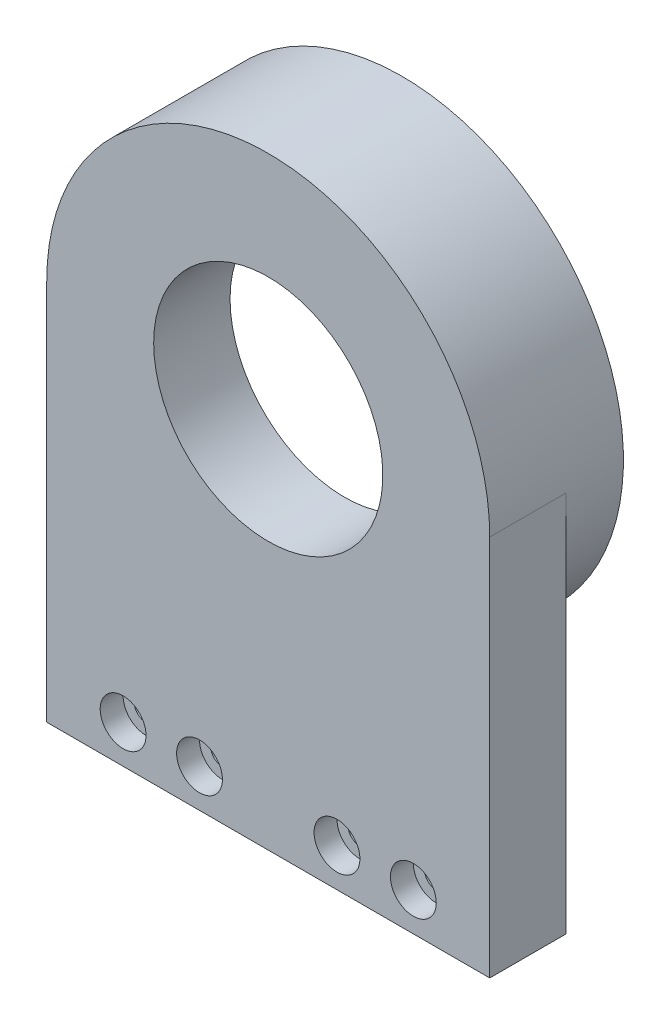
from build123d import *

# Parameters (mm, degrees)
SKETCH_1_W          = 58
SKETCH_1_H          = 50
EXTRUDE_1_DEPTH     = 10
SKETCH_2_R          = 29
SKETCH_2_R_2        = 26.1
EXTRUDE_2_DEPTH     = 7.5
SKETCH_3_R          = 26.1
SKETCH_3_R_2        = 24
EXTRUDE_3_DEPTH     = 0.5
CUT_EXTRUDE_1_REACH = 12
SKETCH_5_R          = 1.55
SKETCH_6_R          = 3
CUT_EXTRUDE_2_DEPTH = 3
SKETCH_7_R          = 15
CUT_EXTRUDE_3_DEPTH = 11


with BuildPart() as part:
    # 草图1 → 凸台-拉伸1 (new body)
    with BuildSketch(Plane.XY):
        with BuildLine():
            ThreePointArc((-29, 25), (0, 54), (29, 25))
            Line((29, 25), (-29, 25))
        make_face()
        Rectangle(SKETCH_1_W, SKETCH_1_H)
    extrude(amount=EXTRUDE_1_DEPTH)

    # 草图2 → 凸台-拉伸2 (add)
    with BuildSketch(Plane(origin=(0, 0, 0), x_dir=(-1, 0, 0), z_dir=(0, 0, -1))):
        with Locations((0, 25)):
            Circle(SKETCH_2_R)
        with Locations((0, 25)):
            Circle(SKETCH_2_R_2, mode=Mode.SUBTRACT)
    extrude(amount=EXTRUDE_2_DEPTH)

    # 草图3 → 凸台-拉伸3 (add)
    with BuildSketch(Plane(origin=(0, 0, 0), x_dir=(-1, 0, 0), z_dir=(0, 0, -1))):
        with Locations((0, 25)):
            Circle(SKETCH_3_R)
        with Locations((0, 25)):
            Circle(SKETCH_3_R_2, mode=Mode.SUBTRACT)
    extrude(amount=EXTRUDE_3_DEPTH)

    # 草图5 → 切除-拉伸1 (cut, up to next)
    with BuildSketch(Plane(origin=(0, 0, 0), x_dir=(-1, 0, 0), z_dir=(0, 0, -1)), mode=Mode.PRIVATE) as cut_extrude_1_sk1:
        with Locations((-19, -20)):
            Circle(SKETCH_5_R)
    cut_extrude_1_tool1 = extrude(cut_extrude_1_sk1.sketch, amount=-CUT_EXTRUDE_1_REACH, mode=Mode.PRIVATE) & part.part
    add(cut_extrude_1_tool1.solids().sort_by_distance((19, -20, 0))[0], mode=Mode.SUBTRACT)
    # 草图5 → 切除-拉伸1 (cut, up to next)
    with BuildSketch(Plane(origin=(0, 0, 0), x_dir=(-1, 0, 0), z_dir=(0, 0, -1)), mode=Mode.PRIVATE) as cut_extrude_1_sk2:
        with Locations((-9, -20)):
            Circle(SKETCH_5_R)
    cut_extrude_1_tool2 = extrude(cut_extrude_1_sk2.sketch, amount=-CUT_EXTRUDE_1_REACH, mode=Mode.PRIVATE) & part.part
    add(cut_extrude_1_tool2.solids().sort_by_distance((9, -20, 0))[0], mode=Mode.SUBTRACT)
    # 草图5 → 切除-拉伸1 (cut, up to next)
    with BuildSketch(Plane(origin=(0, 0, 0), x_dir=(-1, 0, 0), z_dir=(0, 0, -1)), mode=Mode.PRIVATE) as cut_extrude_1_sk3:
        with Locations((9, -20)):
            Circle(SKETCH_5_R)
    cut_extrude_1_tool3 = extrude(cut_extrude_1_sk3.sketch, amount=-CUT_EXTRUDE_1_REACH, mode=Mode.PRIVATE) & part.part
    add(cut_extrude_1_tool3.solids().sort_by_distance((-9, -20, 0))[0], mode=Mode.SUBTRACT)
    # 草图5 → 切除-拉伸1 (cut, up to next)
    with BuildSketch(Plane(origin=(0, 0, 0), x_dir=(-1, 0, 0), z_dir=(0, 0, -1)), mode=Mode.PRIVATE) as cut_extrude_1_sk4:
        with Locations((19, -20)):
            Circle(SKETCH_5_R)
    cut_extrude_1_tool4 = extrude(cut_extrude_1_sk4.sketch, amount=-CUT_EXTRUDE_1_REACH, mode=Mode.PRIVATE) & part.part
    add(cut_extrude_1_tool4.solids().sort_by_distance((-19, -20, 0))[0], mode=Mode.SUBTRACT)

    # 草图6 → 切除-拉伸2 (cut)
    with BuildSketch(Plane.XY.offset(10)):
        with Locations((19, -20)):
            Circle(SKETCH_6_R)
        with Locations((9, -20)):
            Circle(SKETCH_6_R)
        with Locations((-9, -20)):
            Circle(SKETCH_6_R)
        with Locations((-19, -20)):
            Circle(SKETCH_6_R)
    extrude(amount=-CUT_EXTRUDE_2_DEPTH, mode=Mode.SUBTRACT)

    # 草图7 → 切除-拉伸3 (cut, through all)
    with BuildSketch(Plane(origin=(0, 0, 0), x_dir=(-1, 0, 0), z_dir=(0, 0, -1))):
        with Locations((0, 25)):
            Circle(SKETCH_7_R)
    extrude(amount=-CUT_EXTRUDE_3_DEPTH, mode=Mode.SUBTRACT)


solid = part.part
